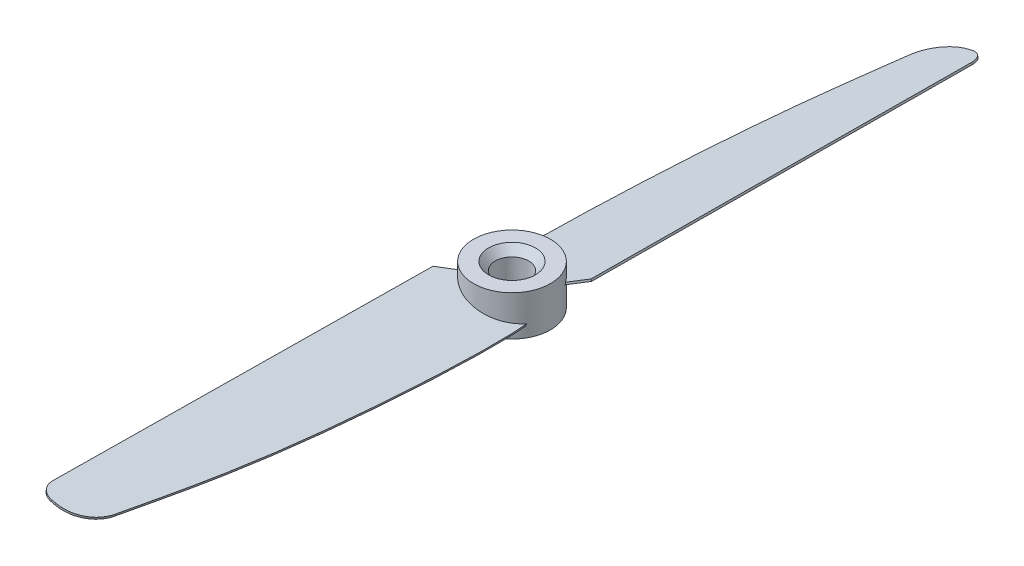
from build123d import *

# Parameters (mm, degrees)
SKETCH1_R             = 5.75
BOSS_EXTRUDE1_DEPTH   = 3
BOSS_EXTRUDE2_DEPTH   = 0.3
CIRPATTERN1_COUNT     = 2
SKETCH4_R             = 2.5
CUT_EXTRUDE1_DEPTH    = 16.3
CHAMFER1_SIZE         = 1
CHAMFER1_SIZE2        = 1.191753593
CHAMFER1_PART_2_SIZE  = 1
CHAMFER1_PART_2_SIZE2 = 1.191753593


with BuildPart() as part:
    # Sketch1 → Boss-Extrude1 (new body, symmetric)
    with BuildSketch(Plane(origin=(0, 0, 0), x_dir=(1, 0, 0), z_dir=(0, 1, 0))):
        Circle(SKETCH1_R)
    extrude(amount=BOSS_EXTRUDE1_DEPTH, both=True)

    # Sketch3 → Boss-Extrude2 (add)
    with BuildSketch(Plane(origin=(0, 0, 0), x_dir=(0.974370065, -0.224951054, 0), z_dir=(-0.224951054, -0.974370065, 0))):
        with BuildLine():
            Line((-6.906213286, 5.083465827), (-4.318560917, 2.607550724))
            Line((-4.318560917, 2.607550724), (5.113121785, 2.549410262))
            add(Edge.make_bspline(
                [(5.113121785, 2.549410262), (5.735638165, 8.028953924), (4.346346729, 38.97674066), (0.38313372, 57.205124306), (0.080525316, 59.236652626)],
                knots=[0, 0, 0, 0, 0.55249972, 0.930981027, 0.930981027, 0.930981027, 0.930981027], degree=3))
            ThreePointArc((0.080525316, 59.236652626), (-1.600195584, 62.287034666), (-4.864911258, 63.5))
            Line((-4.864911258, 63.5), (-5.4532168, 63.5))
            ThreePointArc((-5.4532168, 63.5), (-6.874270643, 62.907340035), (-7.453122766, 61.480605975))
            Line((-7.453122766, 61.480605975), (-6.906213286, 5.083465827))
        make_face()
    boss_extrude2 = extrude(amount=BOSS_EXTRUDE2_DEPTH)

    # CirPattern1: Boss-Extrude2 ×2 about axis
    cirpattern1_axis = Axis((0, -3, 0), (0, 1, 0))
    for i in range(1, CIRPATTERN1_COUNT):
        add(boss_extrude2.rotate(cirpattern1_axis, i * 360 / CIRPATTERN1_COUNT))

    # Sketch4 → Cut-Extrude1 (cut)
    with BuildSketch(Plane.XZ.offset(3)):
        Circle(SKETCH4_R)
    extrude(amount=-CUT_EXTRUDE1_DEPTH, mode=Mode.SUBTRACT)

    # Chamfer1
    chamfer1_edges = [part.edges().sort_by_distance(p)[0] for p in [
        (-2.5, 3, 0),
    ]]
    chamfer1_side = [part.faces().sort_by_distance(p)[0] for p in [
        (-5.58736544, 3, 0),
    ]]
    chamfer(chamfer1_edges, length=CHAMFER1_SIZE, length2=CHAMFER1_SIZE2, reference=chamfer1_side[0])

    # Chamfer1 part 2
    chamfer1_part_2_edges = [part.edges().sort_by_distance(p)[0] for p in [
        (-2.5, -3, 0),
    ]]
    chamfer1_part_2_side = [part.faces().sort_by_distance(p)[0] for p in [
        (-5.58736544, -3, 0),
    ]]
    chamfer(chamfer1_part_2_edges, length=CHAMFER1_PART_2_SIZE, length2=CHAMFER1_PART_2_SIZE2, reference=chamfer1_part_2_side[0])


solid = part.part
